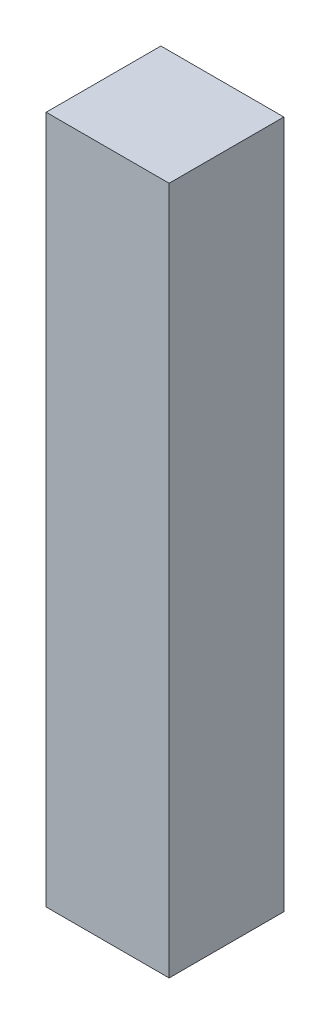
from build123d import *

# Parameters (mm, degrees)
SKETCH1_W           = 3.4036
SKETCH1_H           = 19.05
BOSS_EXTRUDE1_DEPTH = 3.175


with BuildPart() as part:
    # Sketch1 → Boss-Extrude1 (new body)
    with BuildSketch(Plane.XY):
        with Locations((1.7018, -9.525)):
            Rectangle(SKETCH1_W, SKETCH1_H)
    extrude(amount=BOSS_EXTRUDE1_DEPTH)


solid = part.part
